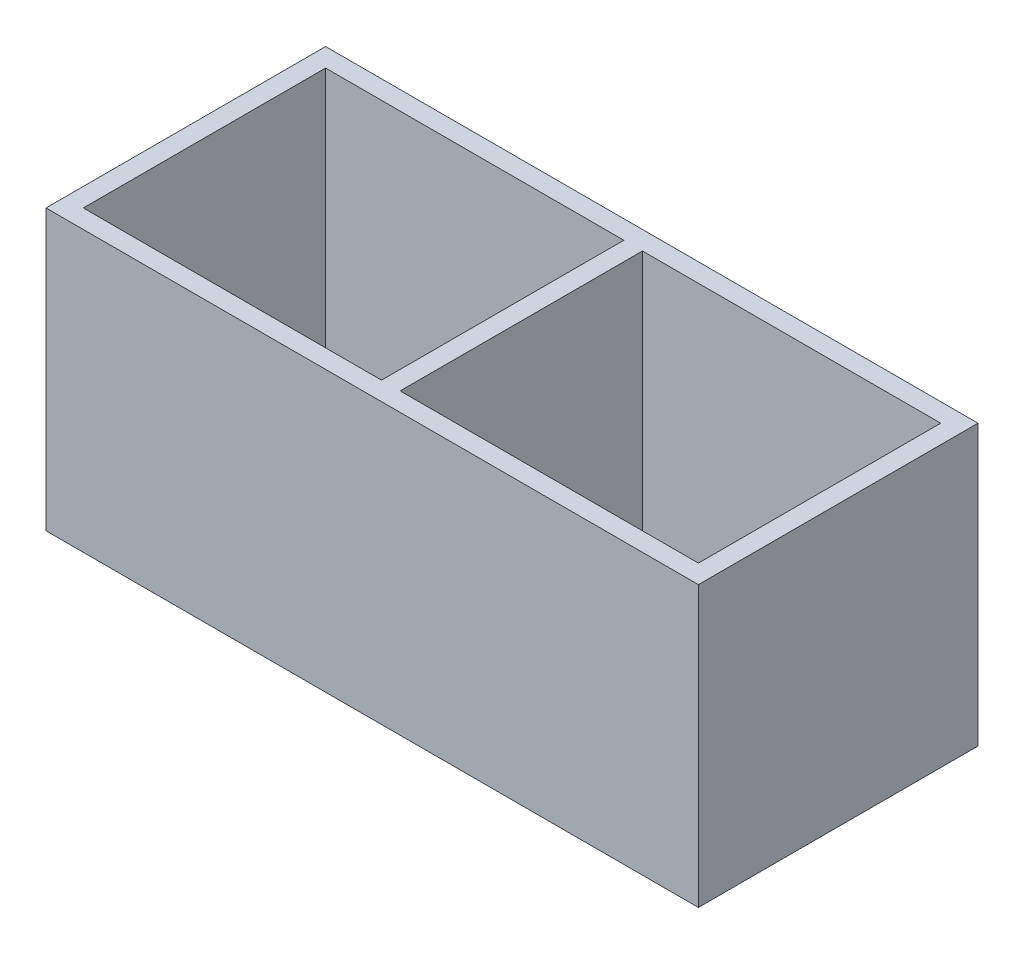
from build123d import *

# Parameters (mm, degrees)
STWOBASE_W     = 35
STWOBASE_H     = 15
STWOBASE_W_2   = 16
STWOBASE_H_2   = 13
FTWOBASE_DEPTH = 15


with BuildPart() as part:
    # STwoBase → FTwoBase (new body)
    with BuildSketch(Plane(origin=(0, 0, 0), x_dir=(1, 0, 0), z_dir=(0, 1, 0))):
        Rectangle(STWOBASE_W, STWOBASE_H)
        with Locations((-8.5, 0)):
            Rectangle(STWOBASE_W_2, STWOBASE_H_2, mode=Mode.SUBTRACT)
        with Locations((8.5, 0)):
            Rectangle(STWOBASE_W_2, STWOBASE_H_2, mode=Mode.SUBTRACT)
    extrude(amount=FTWOBASE_DEPTH)


solid = part.part
